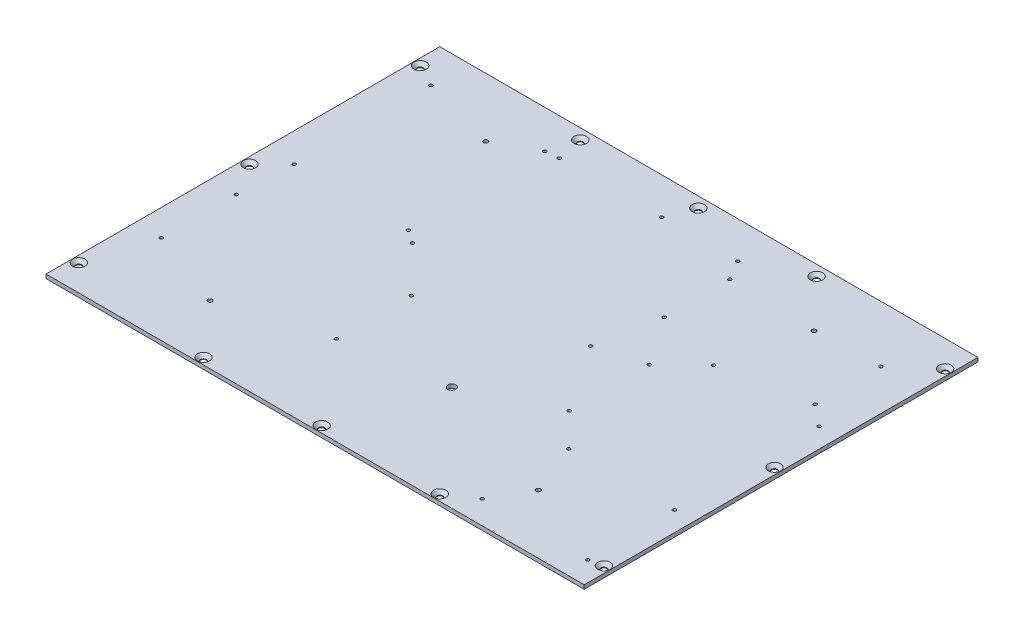
from build123d import *

# Parameters (mm, degrees)
SKETCH_1_W                   = 410
SKETCH_1_H                   = 300
EXTRUDE_1_DEPTH              = 3
HOLE_WIZARD_M4_1_AT_2_COUNT  = 2
HOLE_WIZARD_M4_1_AT_2_PITCH  = 90
HOLE_WIZARD_M4_1_AT_3_COUNT  = 2
HOLE_WIZARD_M4_1_AT_3_PITCH  = 90
HOLE_WIZARD_M4_1_AT_4_COUNT  = 2
HOLE_WIZARD_M4_1_AT_4_PITCH  = 245.283509433
HOLE_WIZARD_M4_1_AT_5_COUNT  = 2
HOLE_WIZARD_M4_1_AT_5_PITCH  = 287
HOLE_WIZARD_M4_1_AT_6_COUNT  = 2
HOLE_WIZARD_M4_1_AT_6_PITCH  = 245.283509433
HOLE_WIZARD_M4_1_AT_7_COUNT  = 2
HOLE_WIZARD_M4_1_AT_7_PITCH  = 200.359676582
HOLE_WIZARD_M4_1_AT_8_COUNT  = 2
HOLE_WIZARD_M4_1_AT_8_PITCH  = 337.615165536
HOLE_WIZARD_M4_1_AT_9_COUNT  = 2
HOLE_WIZARD_M4_1_AT_9_PITCH  = 337.615165536
HOLE_WIZARD_M4_1_AT_10_COUNT = 2
HOLE_WIZARD_M4_1_AT_10_PITCH = 200.359676582
HOLE_WIZARD_M4_1_AT_11_COUNT = 2
HOLE_WIZARD_M4_1_AT_11_PITCH = 300.780650973
HOLE_WIZARD_M4_1_AT_12_COUNT = 2
HOLE_WIZARD_M4_1_AT_12_PITCH = 300.780650973
HOLE_WIZARD_M3_1_D           = 2.5
HOLE_WIZARD_M3_1_CSINK_D     = 3.05
HOLE_WIZARD_M3_1_CSINK_ANGLE = 90
F_6_0MM_1_D                  = 6
HOLE_WIZARD_M4_1_2_D         = 3.3


with BuildPart() as part:
    # 草圖1 → 填料-伸長1 (new body)
    with BuildSketch(Plane(origin=(0, 0, 0), x_dir=(1, 0, 0), z_dir=(0, 1, 0))):
        Rectangle(SKETCH_1_W, SKETCH_1_H)
    extrude(amount=EXTRUDE_1_DEPTH)

    # 草圖3 → Hole Wizard M4 _1 (revolve, cut)
    with BuildSketch(Plane(origin=(0, 3, -142), x_dir=(0, 0, 1), z_dir=(1, 0, 0))):
        Polygon((0, 0), (0, 3), (2.25, 3), (2.25, 2.45), (4.7, 0), align=None)
    hole_wizard_m4_1 = revolve(axis=Axis((0, 9.35, -142), (0, -1, 0)), mode=Mode.SUBTRACT)

    # Hole Wizard M4 _1 at 2: Hole Wizard M4 _1 ×2
    with Locations(*[(-i * HOLE_WIZARD_M4_1_AT_2_PITCH, 0, 0) for i in range(1, HOLE_WIZARD_M4_1_AT_2_COUNT)]):
        add(hole_wizard_m4_1, mode=Mode.SUBTRACT)

    # Hole Wizard M4 _1 at 3: Hole Wizard M4 _1 ×2
    with Locations(*[(i * HOLE_WIZARD_M4_1_AT_3_PITCH, 0, 0) for i in range(1, HOLE_WIZARD_M4_1_AT_3_COUNT)]):
        add(hole_wizard_m4_1, mode=Mode.SUBTRACT)

    # Hole Wizard M4 _1 at 4: Hole Wizard M4 _1 ×2
    with Locations(*[Vector(0.815382985, 0, 0.578921919) * (i * HOLE_WIZARD_M4_1_AT_4_PITCH) for i in range(1, HOLE_WIZARD_M4_1_AT_4_COUNT)]):
        add(hole_wizard_m4_1, mode=Mode.SUBTRACT)

    # Hole Wizard M4 _1 at 5: Hole Wizard M4 _1 ×2
    with Locations(*[(0, 0, i * HOLE_WIZARD_M4_1_AT_5_PITCH) for i in range(1, HOLE_WIZARD_M4_1_AT_5_COUNT)]):
        add(hole_wizard_m4_1, mode=Mode.SUBTRACT)

    # Hole Wizard M4 _1 at 6: Hole Wizard M4 _1 ×2
    with Locations(*[Vector(-0.815382985, 0, 0.578921919) * (i * HOLE_WIZARD_M4_1_AT_6_PITCH) for i in range(1, HOLE_WIZARD_M4_1_AT_6_COUNT)]):
        add(hole_wizard_m4_1, mode=Mode.SUBTRACT)

    # Hole Wizard M4 _1 at 7: Hole Wizard M4 _1 ×2
    with Locations(*[Vector(0.998204845, 0, 0.059892291) * (i * HOLE_WIZARD_M4_1_AT_7_PITCH) for i in range(1, HOLE_WIZARD_M4_1_AT_7_COUNT)]):
        add(hole_wizard_m4_1, mode=Mode.SUBTRACT)

    # Hole Wizard M4 _1 at 8: Hole Wizard M4 _1 ×2
    with Locations(*[Vector(0.59239045, 0, 0.805651013) * (i * HOLE_WIZARD_M4_1_AT_8_PITCH) for i in range(1, HOLE_WIZARD_M4_1_AT_8_COUNT)]):
        add(hole_wizard_m4_1, mode=Mode.SUBTRACT)

    # Hole Wizard M4 _1 at 9: Hole Wizard M4 _1 ×2
    with Locations(*[Vector(-0.59239045, 0, 0.805651013) * (i * HOLE_WIZARD_M4_1_AT_9_PITCH) for i in range(1, HOLE_WIZARD_M4_1_AT_9_COUNT)]):
        add(hole_wizard_m4_1, mode=Mode.SUBTRACT)

    # Hole Wizard M4 _1 at 10: Hole Wizard M4 _1 ×2
    with Locations(*[Vector(-0.998204845, 0, 0.059892291) * (i * HOLE_WIZARD_M4_1_AT_10_PITCH) for i in range(1, HOLE_WIZARD_M4_1_AT_10_COUNT)]):
        add(hole_wizard_m4_1, mode=Mode.SUBTRACT)

    # Hole Wizard M4 _1 at 11: Hole Wizard M4 _1 ×2
    with Locations(*[Vector(0.299221375, 0, 0.954183719) * (i * HOLE_WIZARD_M4_1_AT_11_PITCH) for i in range(1, HOLE_WIZARD_M4_1_AT_11_COUNT)]):
        add(hole_wizard_m4_1, mode=Mode.SUBTRACT)

    # Hole Wizard M4 _1 at 12: Hole Wizard M4 _1 ×2
    with Locations(*[Vector(-0.299221375, 0, 0.954183719) * (i * HOLE_WIZARD_M4_1_AT_12_PITCH) for i in range(1, HOLE_WIZARD_M4_1_AT_12_COUNT)]):
        add(hole_wizard_m4_1, mode=Mode.SUBTRACT)

    # M3 螺紋孔1 (through all)
    with Locations(Plane(origin=(0, 0, 0), x_dir=(-1, 0, 0), z_dir=(0, -1, 0))):
        with Locations((183, 121), (96, 121), (96, 17), (183, 17), (85.936, 121.981), (85.936, 9.967), (-49.954, 9.967), (-49.954, 121.981), (-59.018, 107), (-59.018, 57), (-174.018, 57), (-174.018, 107), (-190, -132.19), (-190, 44), (-109.5, 44), (-109.5, -132.19), (185, -82.202), (51.65, -82.202), (51.65, -25.052), (185, -25.052), (-84.5, -40.9), (-109.5, -66.27), (-190, -66.27), (-84.5, 20.06), (7.958, 121.981)):
            CounterSinkHole(HOLE_WIZARD_M3_1_D / 2, HOLE_WIZARD_M3_1_CSINK_D / 2, counter_sink_angle=HOLE_WIZARD_M3_1_CSINK_ANGLE)

    # Ø6.0mm 定位孔1 (through all)
    with Locations(Plane(origin=(0, 0, 0), x_dir=(-1, 0, 0), z_dir=(0, -1, 0))):
        with Locations((-24.16, -70)):
            Hole(F_6_0MM_1_D / 2)

    # Hole Wizard M4 _1 2 (through all)
    with Locations(Plane(origin=(0, 0, 0), x_dir=(-1, 0, 0), z_dir=(0, -1, 0))):
        with Locations((125, -105), (125, 105), (-125, 105), (-125, -105)):
            Hole(HOLE_WIZARD_M4_1_2_D / 2)


solid = part.part
